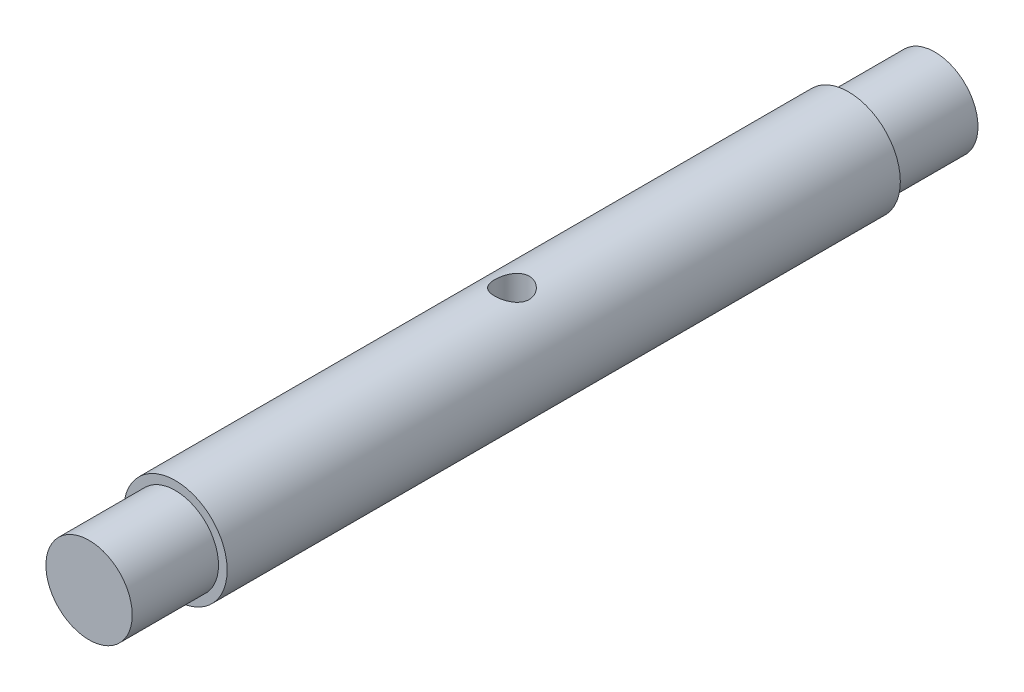
from build123d import *

# Parameters (mm, degrees)
SKETCH2_R               = 1
CUT_EXTRUDE1_DEPTH      = 10
CUT_EXTRUDE1_DEPTH_BACK = 10


with BuildPart() as part:
    # Sketch1 → Revolve1 (revolve)
    with BuildSketch(Plane(origin=(0, 0, 0), x_dir=(1, 0, 0), z_dir=(0, 1, 0))):
        Polygon((0, -24.5), (2.5, -24.5), (2.5, -19.5), (3, -19.5), (3, 19.5), (2.5, 19.5), (2.5, 24.5), (0, 24.5), align=None)
    revolve(axis=Axis((0, 0, 24.5), (0, 0, -1)))

    # Sketch2 → Cut-Extrude1 (cut, two sides)
    with BuildSketch(Plane(origin=(0, 0, 0), x_dir=(1, 0, 0), z_dir=(0, 1, 0))) as cut_extrude1_sk:
        with Locations(Location((0, 0, 0), (0, 0, 90))):  # turned: the seam where the file's is
            Circle(SKETCH2_R)
    extrude(amount=CUT_EXTRUDE1_DEPTH, mode=Mode.SUBTRACT)
    extrude(cut_extrude1_sk.sketch, amount=-CUT_EXTRUDE1_DEPTH_BACK, mode=Mode.SUBTRACT)


solid = part.part
